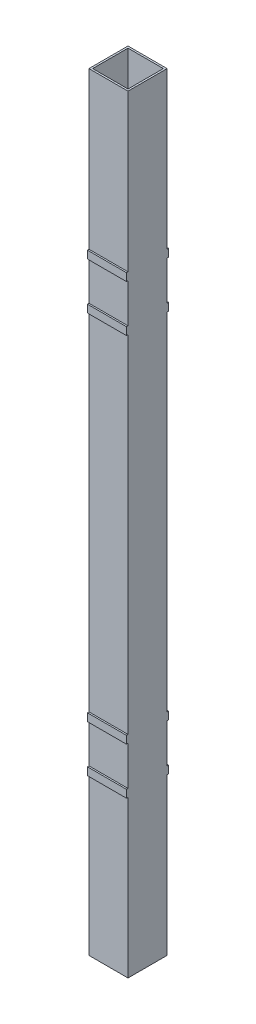
from build123d import *

# Parameters (mm, degrees)
SKETCH1_W                = 25.4
SKETCH1_H                = 25.4
SKETCH1_W_2              = 23
SKETCH1_H_2              = 23
BOSS_EXTRUDE1_DEPTH      = 499.2
SKETCH3_W                = 25.4
SKETCH3_H                = 5
BOSS_EXTRUDE2_DEPTH      = 1
BOSS_EXTRUDE2_DEPTH_BACK = 26.4


with BuildPart() as part:
    # Sketch1 → Boss-Extrude1 (new body)
    with BuildSketch(Plane(origin=(0, 0, 0), x_dir=(1, 0, 0), z_dir=(0, 1, 0))):
        with Locations((12.7, 12.7)):
            Rectangle(SKETCH1_W, SKETCH1_H)
        with Locations((12.7, 12.7)):
            Rectangle(SKETCH1_W_2, SKETCH1_H_2, mode=Mode.SUBTRACT)
    extrude(amount=BOSS_EXTRUDE1_DEPTH)

    # Sketch3 → Boss-Extrude2 (add, two sides)
    with BuildSketch(Plane(origin=(0, 0, -25.4), x_dir=(-1, 0, 0), z_dir=(0, 0, -1))) as boss_extrude2_sk:
        with Locations((-12.7, 104.2)):
            Rectangle(SKETCH3_W, SKETCH3_H)
        with Locations((-12.7, 134.6)):
            Rectangle(SKETCH3_W, SKETCH3_H)
        with Locations((-12.7, 395)):
            Rectangle(SKETCH3_W, SKETCH3_H)
        with Locations((-12.7, 364.6)):
            Rectangle(SKETCH3_W, SKETCH3_H)
    extrude(amount=BOSS_EXTRUDE2_DEPTH)
    extrude(boss_extrude2_sk.sketch, amount=-BOSS_EXTRUDE2_DEPTH_BACK)


solid = part.part
